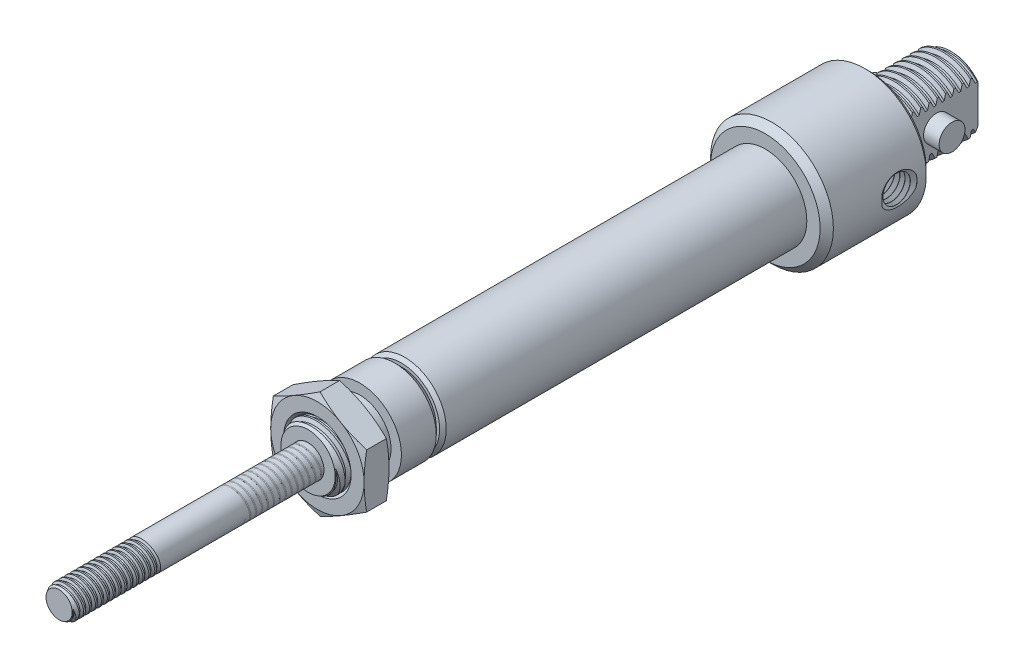
from build123d import *

# Parameters (mm, degrees)
SKETCH1_W           = 90.61450000000005
SKETCH1_H           = 9.398
SKETCH58_W          = 12.699999999999996
SKETCH58_H          = 3.841750000000001
SKETCH59_OUTSIDE_W  = 39.682
SKETCH59_OUTSIDE_H  = 39.682
CUT_EXTRUDE3_DEPTH  = 12.7
CHAMFER1_SIZE       = 0.635
SKETCH4_W           = 7.937499999999986
SKETCH4_H           = 4.7625
LPATTERN2_COUNT     = 2
LPATTERN2_PITCH     = 1.27
LPATTERN2_COL_COUNT = 6
LPATTERN2_COL_PITCH = 1.27
LPATTERN5_COUNT     = 10
LPATTERN5_PITCH     = 1.27
SKETCH60_R          = 1.981200000000002
EXTRUDE2_DEPTH      = 6.35
SKETCH64_W          = 62.039500000000075
SKETCH64_H          = 3.048000000000001
LPATTERN3_COUNT     = 2
LPATTERN3_PITCH     = 0.907142857142857
LPATTERN3_COL_COUNT = 14
LPATTERN3_COL_PITCH = 0.907142857142857
LPATTERN4_COUNT     = 2
LPATTERN4_PITCH     = 25.4
SKETCH54_R          = 4.7625
EXTRUDE1_DEPTH      = 1.9049999999999998


with BuildPart() as part:
    # Sketch1 → Revolve1 (revolve)
    with BuildSketch(Plane(origin=(0, 0, 0), x_dir=(0, 0, -1), z_dir=(1, 0, 0)), mode=Mode.PRIVATE) as revolve1_sk:
        with Locations((10.31874999999999, 4.699)):
            Rectangle(SKETCH1_W, SKETCH1_H)
    revolve(revolve1_sk.sketch.rotate(Axis((0, 0, -55.62600000000001), (0, 0, -1)), 270), axis=Axis((0, 0, -55.62600000000001), (0, 0, -1)))

    # Sketch58 → Cut-Revolve25 (revolve, cut)
    with BuildSketch(Plane(origin=(0, 0, 0), x_dir=(0, 0, -1), z_dir=(1, 0, 0)), mode=Mode.PRIVATE) as cut_revolve25_sk:
        with Locations((49.27600000000001, 7.477124999999999)):
            Rectangle(SKETCH58_W, SKETCH58_H)
    revolve(cut_revolve25_sk.sketch.rotate(Axis((0, 0, -55.62600000000001), (0, 0, -1)), 270), axis=Axis((0, 0, -55.62600000000001), (0, 0, -1)), mode=Mode.SUBTRACT)

    # Sketch59 outside → Cut-Extrude3 (cut)
    with BuildSketch(Plane(origin=(0, 0, -55.62600000000001), x_dir=(-1, 0, 0), z_dir=(0, 0, -1))):
        Rectangle(SKETCH59_OUTSIDE_W, SKETCH59_OUTSIDE_H)
        Polygon((-3.96875, 5.556249999999999), (3.96875, 5.556249999999999), (3.9687500000000018, -5.556249999999998), (-3.96875, -5.556249999999998), align=None, mode=Mode.SUBTRACT)
    extrude(amount=-CUT_EXTRUDE3_DEPTH, mode=Mode.SUBTRACT)

    # Chamfer1
    chamfer1_edges = [part.edges().sort_by_distance(p)[0] for p in [
        (7.949e-14, -5.556249999999999, -55.62600000000001),
        (9.398, 3.24e-15, 34.98850000000004),
        (9.398, 3.24e-15, -42.926000000000016),
        (7.994e-14, 5.556249999999999, -55.62600000000001),
    ]]
    chamfer(chamfer1_edges, length=CHAMFER1_SIZE)



with BuildPart() as body_2:
    # Sketch4 → Revolve2 (revolve)
    with BuildSketch(Plane(origin=(0, 0, 0), x_dir=(0, 0, -1), z_dir=(1, 0, 0)), mode=Mode.PRIVATE) as revolve2_sk:
        with Locations((-38.95725000000002, 2.38125)):
            Rectangle(SKETCH4_W, SKETCH4_H)
    revolve(revolve2_sk.sketch.rotate(Axis((0, 0, 42.926000000000016), (0, 0, -1)), 90), axis=Axis((0, 0, 42.926000000000016), (0, 0, -1)))

    # Sketch5 → Cut-Revolve2 (revolve, cut)
    with BuildSketch(Plane(origin=(0, 0, 0), x_dir=(0, 0, -1), z_dir=(1, 0, 0)), mode=Mode.PRIVATE) as cut_revolve2_sk:
        Polygon((-42.76864257076668, 4.78348099056445), (-41.66714056613308, 4.930347924515599), (-41.96968378508964, 4.196517792153034), (-42.28439864355632, 4.154555811024145), align=None)
    cut_revolve2 = revolve(cut_revolve2_sk.sketch.rotate(Axis((0, -0.18075960345185008, 42.926000000000016), (0, 0.13216372009101784, -0.9912279006826348)), 180), axis=Axis((0, -0.18075960345185008, 42.926000000000016), (0, 0.13216372009101784, -0.9912279006826348)), mode=Mode.SUBTRACT)

    # Sketch6 → Cut-Revolve3 (revolve, cut)
    with BuildSketch(Plane(origin=(0, 0, 0), x_dir=(0, 0, -1), z_dir=(1, 0, 0)), mode=Mode.PRIVATE) as cut_revolve3_sk:
        Polygon((-42.926000000000016, 4.1545558110241405), (-41.873009776527525, 4.762500000000032), (-42.926000000000016, 4.762500000000032), align=None)
    revolve(cut_revolve3_sk.sketch.rotate(Axis((0, 0, 0), (0, -1.2e-16, 1)), 270), axis=Axis((0, 0, 0), (0, -1.2e-16, 1)), mode=Mode.SUBTRACT)

    # LPattern2: Cut-Revolve2 ×2
    with Locations(*[(0, 0, i * LPATTERN2_PITCH) for i in range(1, LPATTERN2_COUNT)]):
        add(cut_revolve2, mode=Mode.SUBTRACT)

    # LPattern2 col: Cut-Revolve2 ×6
    with Locations(*[(0, 0, -i * LPATTERN2_COL_PITCH) for i in range(1, LPATTERN2_COL_COUNT)]):
        add(cut_revolve2, mode=Mode.SUBTRACT)


with BuildPart() as part_1:
    add(part.part)

    add(body_2.part)  # Revolve4 merges body 2
    # Sketch53 → Revolve4 (revolve)
    with BuildSketch(Plane(origin=(0, 0, 0), x_dir=(0, 0, -1), z_dir=(1, 0, 0)), mode=Mode.PRIVATE) as revolve4_sk:
        Polygon((-34.98850000000003, 4.7625), (-36.25849999999997, 4.7625), (-36.25849999999997, 3.209e-14), (-34.98850000000003, 3.216e-14), align=None)
    revolve(revolve4_sk.sketch.rotate(Axis((0, 3.216e-14, 34.98850000000003), (0, -6e-17, 1)), 125.133777622), axis=Axis((0, 3.216e-14, 34.98850000000003), (0, -6e-17, 1)))

    # Sketch62 → Cut-Revolve26 (revolve, cut)
    with BuildSketch(Plane(origin=(0, 0, 0), x_dir=(0, 0, -1), z_dir=(1, 0, 0))):
        Polygon((43.083723311784226, 5.574275521346764), (44.18778649427363, 5.700454170774127), (43.871531011827, 4.972428393536558), (43.55608438825853, 4.936377350843016), align=None)
    cut_revolve26 = revolve(axis=Axis((0, -0.1547457338457372, -42.926000000000016), (0, 0.11354659116073225, -0.9935326726564042)), mode=Mode.SUBTRACT)

    # LPattern5: Cut-Revolve26 ×10
    with Locations(*[(0, 0, -i * LPATTERN5_PITCH) for i in range(1, LPATTERN5_COUNT)]):
        add(cut_revolve26, mode=Mode.SUBTRACT)

    # Sketch60 → Extrude2 (add, symmetric)
    with BuildSketch(Plane(origin=(0, 0, 0), x_dir=(0, 0, -1), z_dir=(1, 0, 0))):
        with Locations(Location((49.27599999999999, 0, 0), (0, 0, 270))):
            Circle(SKETCH60_R)
    extrude(amount=EXTRUDE2_DEPTH, both=True)

    # Sketch63 → Cut-Revolve28 (revolve, cut)
    with BuildSketch(Plane(origin=(0, 0, 0), x_dir=(0, 0, -1), z_dir=(1, 0, 0)), mode=Mode.PRIVATE) as cut_revolve28_sk:
        with BuildLine():
            Line((43.34933333333368, 5.5562499999999995), (45.042666666666676, 5.5562499999999995))
            ThreePointArc((45.042666666666676, 5.5562499999999995), (44.19600000000018, 4.709583333333505), (43.34933333333368, 5.5562499999999995))
        make_face()
    revolve(cut_revolve28_sk.sketch.rotate(Axis((0, 0, -42.926000000000016), (0, 0, -1)), 234.866222378), axis=Axis((0, 0, -42.926000000000016), (0, 0, -1)), mode=Mode.SUBTRACT)

    # Sketch7 → Cut-Revolve5 (revolve, cut)
    with BuildSketch(Plane(origin=(0, 0, 0), x_dir=(0, 0, -1), z_dir=(1, 0, 0)), mode=Mode.PRIVATE) as cut_revolve5_sk:
        Polygon((-42.926000000000016, 2.4383999999999997), (-25.463500000000028, 2.4383999999999997), (-25.463500000000028, 3.9973249999999996), (-14.22399999999999, 3.9973249999999996), (-14.22399999999999, 5.5562499999999995), (-1.5239999999999907, 5.5562499999999995), (23.87600000000001, 5.5562499999999995), (23.87600000000001, -3.209e-14), (-42.926000000000016, -4.034e-14), align=None)
    revolve(cut_revolve5_sk.sketch.rotate(Axis((0, -3.209e-14, -23.87600000000001), (0, 7.2e-16, -1)), 234.866222378), axis=Axis((0, -3.209e-14, -23.87600000000001), (0, 7.2e-16, -1)), mode=Mode.SUBTRACT)

    # Sketch3 → Cut-Revolve1 (revolve, cut)
    with BuildSketch(Plane(origin=(0, 0, 0), x_dir=(0, 0, -1), z_dir=(1, 0, 0)), mode=Mode.PRIVATE) as cut_revolve1_sk:
        Polygon((28.067000000000007, 9.398), (27.051000000000048, 8.382000000000001), (27.051000000000048, 8.89), (26.543000000000042, 9.398), align=None)
        Polygon((-28.63850000000001, 8.382000000000001), (-29.654500000000056, 9.398), (-28.13050000000003, 9.398), (-28.63850000000001, 8.889999999999993), align=None)
    revolve(cut_revolve1_sk.sketch.rotate(Axis((0, 0, -55.62600000000001), (0, 0, -1)), 90), axis=Axis((0, 0, -55.62600000000001), (0, 0, -1)), mode=Mode.SUBTRACT)

    # Sketch64 → Cut-Revolve29 (revolve, cut)
    with BuildSketch(Plane(origin=(0, 0, 0), x_dir=(0, 0, -1), z_dir=(1, 0, 0)), mode=Mode.PRIVATE) as cut_revolve29_sk:
        with Locations((-3.968749999999991, 7.873999999999999)):
            Rectangle(SKETCH64_W, SKETCH64_H)
    revolve(cut_revolve29_sk.sketch.rotate(Axis((0, 0, -55.62600000000001), (0, 0, -1)), 234.866222378), axis=Axis((0, 0, -55.62600000000001), (0, 0, -1)), mode=Mode.SUBTRACT)

    # Sketch65 → Cut-Revolve30 (revolve, cut)
    with BuildSketch(Plane(origin=(0, 0, 0), x_dir=(0, 0, -1), z_dir=(1, 0, 0)), mode=Mode.PRIVATE) as cut_revolve30_sk:
        Polygon((-29.654500000000084, 6.35), (-28.63850000000001, 5.3340000000000005), (-28.63850000000001, 5.841999999999929), (-28.130499999999948, 6.35), align=None)
    revolve(cut_revolve30_sk.sketch.rotate(Axis((0, 0, 28.63850000000001), (0, 0, -1)), 180), axis=Axis((0, 0, 28.63850000000001), (0, 0, -1)), mode=Mode.SUBTRACT)

    # Sketch13 → Cut-Revolve22 (revolve, cut)
    with BuildSketch(Plane(origin=(-356.43189831156747, -1.751719437413847, -38.16350000000246), x_dir=(1, 0, 0), z_dir=(0, 0, 1)), mode=Mode.PRIVATE) as cut_revolve22_sk:
        Polygon((355.87309831156927, 1.7517194374138465), (355.87309831156927, 3.821015605286876), (355.88822128018296, 3.8472093552869717), (356.2548503429557, 4.482229519540826), (356.2850962801829, 4.482229519540826), (356.65172534295573, 3.8472093552869717), (356.6819712801829, 3.8472093552869717), (357.0486003429557, 4.482229519540826), (357.07884628018286, 4.482229519540826), (357.4454753429557, 3.8472093552869717), (357.4757212801829, 3.8472093552869717), (357.8423503429557, 4.482229519540826), (357.87259628018285, 4.482229519540826), (358.2392253429557, 3.8472093552869717), (358.26947128018287, 3.8472093552869717), (358.6361003429557, 4.482229519540826), (358.66634628018284, 4.482229519540826), (359.0329753429557, 3.8472093552869717), (359.06322128018286, 3.8472093552869717), (359.42985034295566, 4.482229519540826), (359.4600962801828, 4.482229519540826), (359.8267253429557, 3.8472093552869717), (359.85697128018285, 3.8472093552869717), (360.22360034295565, 4.482229519540826), (360.2538462801828, 4.482229519540826), (360.6204753429557, 3.8472093552869717), (360.65072128018284, 3.8472093552869717), (361.01735034295564, 4.482229519540826), (361.0475962801828, 4.482229519540826), (361.41422534295566, 3.8472093552869717), (361.4444712801828, 3.8472093552869717), (361.8111003429556, 4.482229519540826), (361.8413462801828, 4.482229519540826), (362.20797534295565, 3.8472093552869717), (362.2382212801828, 3.8472093552869717), (362.6048503429556, 4.482229519540826), (362.6350962801828, 4.482229519540826), (363.0017253429556, 3.8472093552869717), (363.0319712801828, 3.8472093552869717), (363.39860034295555, 4.482229519540826), (363.4288462801827, 4.482229519540826), (363.79547534295557, 3.8472093552869717), (363.82572128018273, 3.8472093552869717), (364.19235034295554, 4.482229519540826), (364.2225962801827, 4.482229519540826), (364.58922534295556, 3.8472093552869717), (364.6194712801827, 3.8472093552869717), (364.9861003429555, 4.482229519540826), (365.0163462801827, 4.482229519540826), (365.38297534295555, 3.8472093552869717), (365.4132212801827, 3.8472093552869717), (365.7798503429555, 4.482229519540826), (365.8100962801827, 4.482229519540826), (366.17672534295554, 3.8472093552869717), (366.2069712801827, 3.8472093552869717), (366.5736003429555, 4.482229519540826), (366.60384628018267, 4.482229519540826), (366.9704753429555, 3.8472093552869717), (367.0007212801827, 3.8472093552869717), (367.3673503429555, 4.482229519540826), (367.39759628018265, 4.482229519540826), (367.7642253429555, 3.8472093552869717), (367.7944712801827, 3.8472093552869717), (367.7944712801827, 1.7517194374138465), align=None)
    revolve(cut_revolve22_sk.sketch.rotate(Axis((-0.5587999999981941, -4.3e-16, -38.16350000000246), (-1, 0, 0)), 90), axis=Axis((-0.5587999999981941, -4.3e-16, -38.16350000000246), (-1, 0, 0)), mode=Mode.SUBTRACT)


with BuildPart() as body_2_2:
    # Sketch8 → Revolve3 (revolve)
    with BuildSketch(Plane(origin=(0, 0, 0), x_dir=(0, 0, -1), z_dir=(1, 0, 0)), mode=Mode.PRIVATE) as revolve3_sk:
        Polygon((11.17600000000002, 5.505450000000001), (23.87600000000001, 5.50545), (23.87600000000001, -3.216e-14), (-55.62600000000001, -4.19e-14), (-55.62600000000001, 2.413), (11.17600000000002, 2.413), align=None)
    revolve(revolve3_sk.sketch.rotate(Axis((0, -3.216e-14, -23.87600000000001), (0, -1.2e-16, 1)), 270), axis=Axis((0, -3.216e-14, -23.87600000000001), (0, -1.2e-16, 1)))

    # Sketch10 → Cut-Revolve6 (revolve, cut)
    with BuildSketch(Plane(origin=(0, 0, 0), x_dir=(0, 0, -1), z_dir=(1, 0, 0)), mode=Mode.PRIVATE) as cut_revolve6_sk:
        Polygon((-55.51455881170136, 2.4339475917854423), (-54.734470493610964, 2.580580734283632), (-54.922367731186085, 2.045657254347334), (-55.14525010778326, 2.0037620707764416), align=None)
    cut_revolve6 = revolve(cut_revolve6_sk.sketch.rotate(Axis((0, -0.1828525570588455, 55.62600000000001), (0, 0.1847346677142573, -0.9827884322398708)), 180), axis=Axis((0, -0.1828525570588455, 55.62600000000001), (0, 0.1847346677142573, -0.9827884322398708)), mode=Mode.SUBTRACT)

    # Sketch11 → Cut-Revolve7 (revolve, cut)
    with BuildSketch(Plane(origin=(0, 0, 0), x_dir=(0, 0, -1), z_dir=(1, 0, 0)), mode=Mode.PRIVATE) as cut_revolve7_sk:
        Polygon((-55.62600000000001, 2.413), (-54.91717911420052, 2.4129999999999985), (-55.62600000000001, 2.0037620707764416), align=None)
    revolve(cut_revolve7_sk.sketch.rotate(Axis((0, 0, 0), (0, -1.2e-16, 1)), 270), axis=Axis((0, 0, 0), (0, -1.2e-16, 1)), mode=Mode.SUBTRACT)

    # LPattern3: Cut-Revolve6 ×2
    with Locations(*[(0, 0, i * LPATTERN3_PITCH) for i in range(1, LPATTERN3_COUNT)]):
        add(cut_revolve6, mode=Mode.SUBTRACT)

    # LPattern3 col: Cut-Revolve6 ×14
    with Locations(*[(0, 0, -i * LPATTERN3_COL_PITCH) for i in range(1, LPATTERN3_COL_COUNT)]):
        add(cut_revolve6, mode=Mode.SUBTRACT)


with BuildPart() as lpattern4_1:
    # LPattern4: pattern copy
    add(body_2_2.part.moved(Location(Vector(0, 5e-17, 1) * (1 * LPATTERN4_PITCH))))


with BuildPart() as body_4:
    # Sketch54 → Extrude1 (new, symmetric)
    with BuildSketch(Plane.XY.offset(39.59224999999999)):
        Polygon((1.4e-16, 8.24889197104678), (-7.1437500000000025, 4.124445985523392), (-7.143750000000002, -4.12444598552339), (-4.2e-15, -8.248891971046778), (7.143749999999995, -4.1244459855233915), (7.1437499999999945, 4.124445985523395), align=None)
        with Locations(Location((0, 0, 0), (0, 0, 180))):
            Circle(SKETCH54_R, mode=Mode.SUBTRACT)
    extrude(amount=EXTRUDE1_DEPTH, both=True)

    # Sketch55 → Cut-Revolve24 (revolve, cut)
    with BuildSketch(Plane(origin=(0, 0, 0), x_dir=(0, 0, -1), z_dir=(1, 0, 0)), mode=Mode.PRIVATE) as cut_revolve24_sk:
        Polygon((-41.09501121790069, 8.24889197104678), (-41.49724999999999, 8.248891971046811), (-41.49724999999999, 7.1437499999999945), align=None)
        Polygon((-38.08948878209928, 8.24889197104678), (-37.687250000000006, 8.24889197104678), (-37.687250000000006, 7.1437499999999945), align=None)
        Polygon((-41.49724999999999, 5.164738782099354), (-41.49724999999999, 4.7625), (-41.09501121790071, 4.7625), align=None)
        Polygon((-37.68725, 5.1647387820993), (-37.687250000000006, 4.762500000000032), (-38.08948878209928, 4.762500000000033), align=None)
    revolve(cut_revolve24_sk.sketch.rotate(Axis((0, 0, 0), (0, -1.2e-16, 1)), 125.382451237), axis=Axis((0, 0, 0), (0, -1.2e-16, 1)), mode=Mode.SUBTRACT)


solid = Compound([part_1.part, body_2_2.part, lpattern4_1.part, body_4.part])
